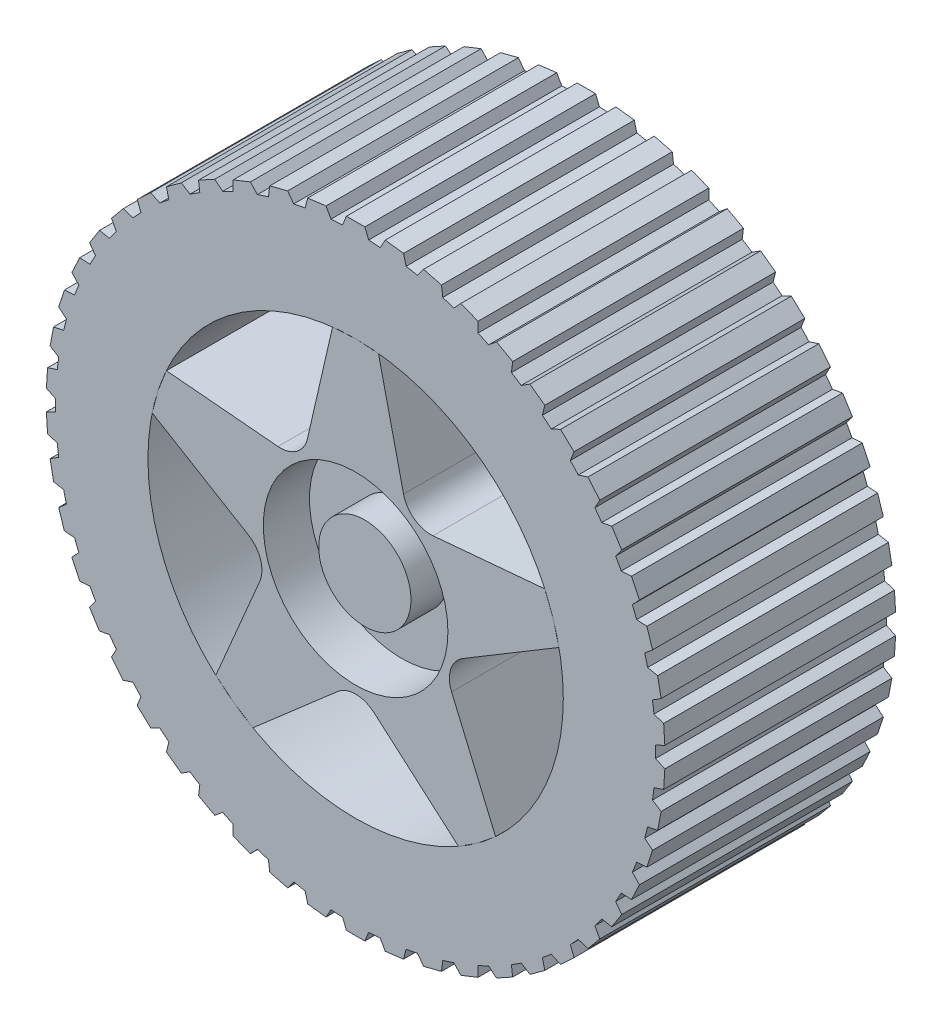
from build123d import *

# Parameters (mm, degrees)
BOSS_EXTRUDE3_DEPTH   = 25
SKETCH1_R             = 32.5
BOSS_EXTRUDE3_2_DEPTH = 25
SKETCH1_13_R          = 5
CUT_EXTRUDE8_DEPTH    = 1
SKETCH1_14_R          = 10
SKETCH1_14_R_2        = 5
CUT_EXTRUDE9_DEPTH    = 5
BOSS_EXTRUDE4_DEPTH   = 25
SKETCH8_R             = 22.5
CUT_EXTRUDE10_DEPTH   = 10


with BuildPart() as part:
    # Sketch1 → Boss-Extrude3 (new body)
    with BuildSketch(Plane.XY):
        with BuildLine():
            Line((2.471852483, 22.362462449), (0, 22.5))
            Line((0, 22.5), (-2.496138994, 22.361111111))
            Line((-2.496138994, 22.361111111), (-5.221015579, 10.507904026))
            ThreePointArc((-5.221015579, 10.507904026), (-6.381398701, 8.752977267), (-8.409011335, 8.19168953))
            Line((-8.409011335, 8.19168953), (-20.504121207, 9.261252344))
            Line((-20.504121207, 9.261252344), (-21.398771617, 6.952882373))
            Line((-21.398771617, 6.952882373), (-22.038029803, 4.535994091))
            Line((-22.038029803, 4.535994091), (-11.606993139, -1.718359969))
            ThreePointArc((-11.606993139, -1.718359969), (-10.296536713, -3.364252091), (-10.389287116, -5.466073748))
            Line((-10.389287116, -5.466073748), (-15.144096299, -16.638693721))
            Line((-15.144096299, -16.638693721), (-13.225168177, -18.202882373))
            Line((-13.225168177, -18.202882373), (-11.12411247, -19.55771259))
            Line((-11.12411247, -19.55771259), (-1.952500687, -11.569908892))
            ThreePointArc((-1.952500687, -11.569908892), (0.017789046, -10.832199406), (1.988078779, -11.569908892))
            Line((1.988078779, -11.569908892), (11.144554966, -19.544530593))
            Line((11.144554966, -19.544530593), (13.225168177, -18.202882373))
            Line((13.225168177, -18.202882373), (15.162950202, -16.623325214))
            Line((15.162950202, -16.623325214), (10.400281351, -5.432236973))
            ThreePointArc((10.400281351, -5.432236973), (10.307530948, -3.330415315), (11.617987373, -1.684523194))
            Line((11.617987373, -1.684523194), (22.031810057, 4.559509521))
            Line((22.031810057, 4.559509521), (21.398771617, 6.952882373))
            Line((21.398771617, 6.952882373), (20.495331064, 9.283932602))
            Line((20.495331064, 9.283932602), (8.380228055, 8.212601808))
            ThreePointArc((8.380228055, 8.212601808), (6.35261542, 8.773889544), (5.192232299, 10.528816304))
            Line((5.192232299, 10.528816304), (2.471852483, 22.362462449))
        make_face()
    extrude(amount=-BOSS_EXTRUDE3_DEPTH)

    # Sketch1_13 → Cut-Extrude8 (cut)
    with BuildSketch(Plane.XY):
        Circle(SKETCH1_13_R)
    extrude(amount=-CUT_EXTRUDE8_DEPTH, mode=Mode.SUBTRACT)

    # Sketch1_14 → Cut-Extrude9 (cut)
    with BuildSketch(Plane.XY):
        Circle(SKETCH1_14_R)
        Circle(SKETCH1_14_R_2, mode=Mode.SUBTRACT)
    extrude(amount=-CUT_EXTRUDE9_DEPTH, mode=Mode.SUBTRACT)

    # Sketch8 → Cut-Extrude10 (cut)
    with BuildSketch(Plane(origin=(0, 0, -25), x_dir=(-1, 0, 0), z_dir=(0, 0, -1))):
        Circle(SKETCH8_R)
    extrude(amount=-CUT_EXTRUDE10_DEPTH, mode=Mode.SUBTRACT)


with BuildPart() as body_2:
    # Sketch1 → Boss-Extrude3 2 (new body)
    with BuildSketch(Plane.XY):
        Circle(SKETCH1_R)
        with BuildLine():
            ThreePointArc((-2.496138994, 22.361111111), (-1.25, 22.465250945), (0, 22.5))
            ThreePointArc((0, 22.5), (12.193471951, 18.909501362), (20.495331064, 9.283932602))
            ThreePointArc((20.495331064, 9.283932602), (20.979452058, 8.13096497), (21.398771617, 6.952882373))
            ThreePointArc((21.398771617, 6.952882373), (21.751994544, -5.753323679), (15.162950202, -16.623325214))
            ThreePointArc((15.162950202, -16.623325214), (14.216014437, -17.440038232), (13.225168177, -18.202882373))
            ThreePointArc((13.225168177, -18.202882373), (1.25, -22.465250945), (-11.12411247, -19.55771259))
            ThreePointArc((-11.12411247, -19.55771259), (-12.193471951, -18.909501362), (-13.225168177, -18.202882373))
            ThreePointArc((-13.225168177, -18.202882373), (-20.979452058, -8.13096497), (-22.038029803, 4.535994091))
            ThreePointArc((-22.038029803, 4.535994091), (-21.751994544, 5.753323679), (-21.398771617, 6.952882373))
            ThreePointArc((-21.398771617, 6.952882373), (-14.216014437, 17.440038232), (-2.496138994, 22.361111111))
        make_face(mode=Mode.SUBTRACT)
    extrude(amount=-BOSS_EXTRUDE3_2_DEPTH)

    # Sketch7 → Boss-Extrude4 (add)
    with BuildSketch(Plane.XY):
        Polygon((-1.6, 32), (1.6, 32), (1, 33.5), (-1, 33.5), align=None)
        Polygon((2.423279952, 31.948203616), (5.598046996, 31.547137268), (5.190778026, 33.11050926), (3.206548623, 33.361175728), align=None)
        Polygon((6.408343331, 31.392564976), (9.507809447, 30.596757337), (9.299694381, 32.198846011), (7.362528059, 32.696225785), align=None)
        Polygon((10.292343308, 30.341846833), (13.267628063, 29.163848264), (13.261949001, 30.779387725), (11.402396029, 31.51563683), align=None)
        Polygon((14.014026883, 28.81261964), (16.818208259, 27.271007883), (17.015054762, 28.874520107), (15.262441402, 29.838027456), align=None)
        Polygon((17.514700882, 26.829000224), (20.103555264, 24.948087416), (20.499822946, 26.514284059), (18.881788957, 27.689854564), align=None)
        Polygon((20.739157586, 24.422271447), (23.071857194, 22.231720708), (23.661296676, 23.735901913), (22.203359421, 25.104996125), align=None)
        Polygon((23.636545385, 21.63038886), (25.676302152, 19.164746484), (26.449617623, 20.583190414), (25.174769643, 22.124216899), align=None)
        Polygon((26.161170744, 18.49738212), (27.875816488, 15.795532759), (28.820812299, 17.105869706), (27.749158709, 18.794525557), align=None)
        Polygon((28.273218812, 15.072660614), (29.635712545, 12.177214046), (30.737485549, 13.358779215), (29.885926966, 15.16843332), align=None)
        Polygon((29.93938133, 11.410234246), (30.928235712, 8.366853394), (32.16941029, 9.401012795), (31.551376302, 11.303125828), align=None)
        Polygon((31.13338192, 7.567861668), (31.733002127, 4.424542466), (33.094004214, 5.294986788), (32.719241585, 7.259561289), align=None)
        Polygon((31.836390478, 3.60613939), (32.037320141, 0.412453859), (33.496685922, 1.105455676), (33.371104883, 3.101509133), align=None)
        Polygon((32.037320141, -0.412453859), (31.836390478, -3.60613939), (33.371104883, -3.101509133), (33.496685922, -1.105455676), align=None)
        Polygon((31.733002127, -4.424542466), (31.13338192, -7.567861668), (32.719241585, -7.259561289), (33.094004214, -5.294986788), align=None)
        Polygon((30.928235712, -8.366853394), (29.93938133, -11.410234246), (31.551376302, -11.303125828), (32.16941029, -9.401012795), align=None)
        Polygon((29.635712545, -12.177214046), (28.273218812, -15.072660614), (29.885926966, -15.16843332), (30.737485549, -13.358779215), align=None)
        Polygon((27.875816488, -15.795532759), (26.161170744, -18.49738212), (27.749158709, -18.794525557), (28.820812299, -17.105869706), align=None)
        Polygon((25.676302152, -19.164746484), (23.636545385, -21.63038886), (25.174769643, -22.124216899), (26.449617623, -20.583190414), align=None)
        Polygon((23.071857194, -22.231720708), (20.739157586, -24.422271447), (22.203359421, -25.104996125), (23.661296676, -23.735901913), align=None)
        Polygon((20.103555264, -24.948087416), (17.514700882, -26.829000224), (18.881788957, -27.689854564), (20.499822946, -26.514284059), align=None)
        Polygon((16.818208259, -27.271007883), (14.014026883, -28.81261964), (15.262441402, -29.838027456), (17.015054762, -28.874520107), align=None)
        Polygon((13.267628063, -29.163848264), (10.292343308, -30.341846833), (11.402396029, -31.51563683), (13.261949001, -30.779387725), align=None)
        Polygon((9.507809447, -30.596757337), (6.408343331, -31.392564976), (7.362528059, -32.696225785), (9.299694381, -32.198846011), align=None)
        Polygon((5.598046996, -31.547137268), (2.423279952, -31.948203616), (3.206548623, -33.361175728), (5.190778026, -33.11050926), align=None)
        Polygon((1.6, -32), (-1.6, -32), (-1, -33.5), (1, -33.5), align=None)
        Polygon((-2.423279952, -31.948203616), (-5.598046996, -31.547137268), (-5.190778026, -33.11050926), (-3.206548623, -33.361175728), align=None)
        Polygon((-6.408343331, -31.392564976), (-9.507809447, -30.596757337), (-9.299694381, -32.198846011), (-7.362528059, -32.696225785), align=None)
        Polygon((-10.292343308, -30.341846833), (-13.267628063, -29.163848264), (-13.261949001, -30.779387725), (-11.402396029, -31.51563683), align=None)
        Polygon((-14.014026883, -28.81261964), (-16.818208259, -27.271007883), (-17.015054762, -28.874520107), (-15.262441402, -29.838027456), align=None)
        Polygon((-17.514700882, -26.829000224), (-20.103555264, -24.948087416), (-20.499822946, -26.514284059), (-18.881788957, -27.689854564), align=None)
        Polygon((-20.739157586, -24.422271447), (-23.071857194, -22.231720708), (-23.661296676, -23.735901913), (-22.203359421, -25.104996125), align=None)
        Polygon((-23.636545385, -21.63038886), (-25.676302152, -19.164746484), (-26.449617623, -20.583190414), (-25.174769643, -22.124216899), align=None)
        Polygon((-26.161170744, -18.49738212), (-27.875816488, -15.795532759), (-28.820812299, -17.105869706), (-27.749158709, -18.794525557), align=None)
        Polygon((-28.273218812, -15.072660614), (-29.635712545, -12.177214046), (-30.737485549, -13.358779215), (-29.885926966, -15.16843332), align=None)
        Polygon((-29.93938133, -11.410234246), (-30.928235712, -8.366853394), (-32.16941029, -9.401012795), (-31.551376302, -11.303125828), align=None)
        Polygon((-31.13338192, -7.567861668), (-31.733002127, -4.424542466), (-33.094004214, -5.294986788), (-32.719241585, -7.259561289), align=None)
        Polygon((-31.836390478, -3.60613939), (-32.037320141, -0.412453859), (-33.496685922, -1.105455676), (-33.371104883, -3.101509133), align=None)
        Polygon((-32.037320141, 0.412453859), (-31.836390478, 3.60613939), (-33.371104883, 3.101509133), (-33.496685922, 1.105455676), align=None)
        Polygon((-31.733002127, 4.424542466), (-31.13338192, 7.567861668), (-32.719241585, 7.259561289), (-33.094004214, 5.294986788), align=None)
        Polygon((-30.928235712, 8.366853394), (-29.93938133, 11.410234246), (-31.551376302, 11.303125828), (-32.16941029, 9.401012795), align=None)
        Polygon((-29.635712545, 12.177214046), (-28.273218812, 15.072660614), (-29.885926966, 15.16843332), (-30.737485549, 13.358779215), align=None)
        Polygon((-27.875816488, 15.795532759), (-26.161170744, 18.49738212), (-27.749158709, 18.794525557), (-28.820812299, 17.105869706), align=None)
        Polygon((-25.676302152, 19.164746484), (-23.636545385, 21.63038886), (-25.174769643, 22.124216899), (-26.449617623, 20.583190414), align=None)
        Polygon((-23.071857194, 22.231720708), (-20.739157586, 24.422271447), (-22.203359421, 25.104996125), (-23.661296676, 23.735901913), align=None)
        Polygon((-20.103555264, 24.948087416), (-17.514700882, 26.829000224), (-18.881788957, 27.689854564), (-20.499822946, 26.514284059), align=None)
        Polygon((-16.818208259, 27.271007883), (-14.014026883, 28.81261964), (-15.262441402, 29.838027456), (-17.015054762, 28.874520107), align=None)
        Polygon((-13.267628063, 29.163848264), (-10.292343308, 30.341846833), (-11.402396029, 31.51563683), (-13.261949001, 30.779387725), align=None)
        Polygon((-9.507809447, 30.596757337), (-6.408343331, 31.392564976), (-7.362528059, 32.696225785), (-9.299694381, 32.198846011), align=None)
        Polygon((-5.598046996, 31.547137268), (-2.423279952, 31.948203616), (-3.206548623, 33.361175728), (-5.190778026, 33.11050926), align=None)
    extrude(amount=-BOSS_EXTRUDE4_DEPTH)


solid = Compound([part.part, body_2.part])
